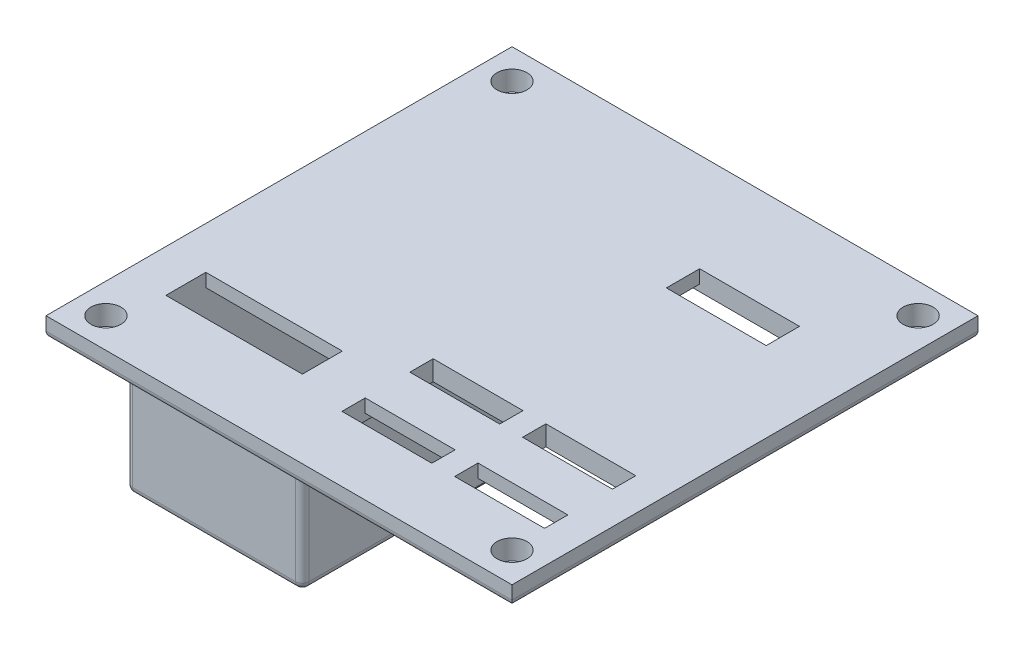
from build123d import *

# Parameters (mm, degrees)
BOSS_EXTRUDE1_DEPTH                        = 3
SKETCH4_R                                  = 2.250000000000006
CUT_EXTRUDE2_DEPTH                         = 3
MIRROR1_AT_THE_SECOND_PLANE_COPY_1_SKETC_R = 2.250000000000006
MIRROR1_AT_THE_SECOND_PLANE_COPY_1_DEPTH   = 3
FILLET4_R                                  = 1
CUT_EXTRUDE3_DEPTH                         = 1
SKETCH6_W                                  = 27.499999999999993
SKETCH6_H                                  = 27.999999999999996
CUT_EXTRUDE4_DEPTH                         = 1
CUT_EXTRUDE5_DEPTH                         = 3
SKETCH8_W                                  = 13.499999999999996
SKETCH8_H                                  = 13.700000000000003
CUT_EXTRUDE6_DEPTH                         = 1
SKETCH9_W                                  = 13.5
SKETCH9_H                                  = 3.5000000000000036
CUT_EXTRUDE7_DEPTH                         = 3
SKETCH10_W                                 = 13.499999999999996
SKETCH10_H                                 = 3.5000000000000036
SKETCH10_H_2                               = 3.5000000000000018
CUT_EXTRUDE8_DEPTH                         = 3
BOSS_EXTRUDE2_DEPTH                        = 23.5
CUT_EXTRUDE9_DEPTH                         = 29
SKETCH13_W                                 = 20.500000000000004
SKETCH13_H                                 = 6.0000000000000036
CUT_EXTRUDE10_DEPTH                        = 3
FILLET5_R                                  = 1
FILLET6_R                                  = 1
SKETCH14_W                                 = 20.8
SKETCH14_H                                 = 3.0000000000000036
CUT_EXTRUDE11_DEPTH                        = 1


with BuildPart() as part:
    # Sketch1 → Boss-Extrude1 (new body)
    with BuildSketch(Plane(origin=(0, 0, 0), x_dir=(1, 0, 0), z_dir=(0, 1, 0))):
        Polygon((-35, 35.00000000000001), (35, 35.00000000000001), (35.000000000000014, -34.99999999999999), (-35, -34.99999999999999), align=None)
    extrude(amount=BOSS_EXTRUDE1_DEPTH)

    # Sketch4 → Cut-Extrude2 (cut)
    with BuildSketch(Plane(origin=(0, 0, 0), x_dir=(-1, 0, 0), z_dir=(0, -1, 0))):
        with Locations(Location((30.500000000000004, -30.499999999999993, 0), (0, 0, 90))):
            Circle(SKETCH4_R)
    cut_extrude2 = extrude(amount=-CUT_EXTRUDE2_DEPTH, mode=Mode.SUBTRACT)

    # Mirror1: Cut-Extrude2 across plane
    add(cut_extrude2.mirror(Plane(origin=(0, 0, 0), x_dir=(0, 0, 1), z_dir=(1, 0, 0))), mode=Mode.SUBTRACT)

    # Mirror1 at the second plane: Cut-Extrude2 across plane
    add(cut_extrude2.mirror(Plane.XY), mode=Mode.SUBTRACT)

    # Mirror1 at the second plane copy 1 sketc → Mirror1 at the second plane copy 1 (cut)
    with BuildSketch(Plane.XZ):
        with Locations(Location((30.500000000000004, -30.499999999999993, 0), (0, 0, 90))):
            Circle(MIRROR1_AT_THE_SECOND_PLANE_COPY_1_SKETC_R)
    extrude(amount=-MIRROR1_AT_THE_SECOND_PLANE_COPY_1_DEPTH, mode=Mode.SUBTRACT)

    # Fillet4
    fillet4_edges = [part.edges().sort_by_distance(p)[0] for p in [
        (7.11e-15, 0, 34.99999999999999),
        (-35, 0, -7.11e-15),
        (0, 0, -35.00000000000001),
        (35.00000000000001, 0, -7.11e-15),
    ]]
    fillet(fillet4_edges, radius=FILLET4_R)

    # Sketch5 → Cut-Extrude3 (cut)
    with BuildSketch(Plane(origin=(0, 0, 0), x_dir=(-1, 0, 0), z_dir=(0, -1, 0))):
        Polygon((28.79465847473562, -24.725896818258043), (7.994658474735617, -24.725896818258047), (7.994658474735617, 20.774103181741953), (28.79465847473562, 20.774103181741957), align=None)
    extrude(amount=-CUT_EXTRUDE3_DEPTH, mode=Mode.SUBTRACT)

    # Sketch6 → Cut-Extrude4 (cut)
    with BuildSketch(Plane.XZ):
        with Locations((15.477858409688114, -6.209961428811168)):
            Rectangle(SKETCH6_W, SKETCH6_H)
    extrude(amount=-CUT_EXTRUDE4_DEPTH, mode=Mode.SUBTRACT)

    # Sketch7 → Cut-Extrude5 (cut)
    with BuildSketch(Plane(origin=(0, 1, 0), x_dir=(-1, 0, 0), z_dir=(0, -1, 0))):
        Polygon((-7.977858409688114, 15.209961428811162), (-22.977858409688114, 15.20996142881116), (-22.977858409688114, 20.209961428811166), (-7.977858409688114, 20.209961428811166), align=None)
    extrude(amount=-CUT_EXTRUDE5_DEPTH, mode=Mode.SUBTRACT)

    # Sketch8 → Cut-Extrude6 (cut)
    with BuildSketch(Plane.XZ):
        Polygon((-0.32931613637633694, 25.216207013959828), (13.170683863623664, 25.216207013959828), (13.170683863623664, 11.516207013959828), (-0.3293161363763353, 11.516207013959828), align=None)
        with Locations((23.356942305835496, 18.36620701395983)):
            Rectangle(SKETCH8_W, SKETCH8_H)
    extrude(amount=-CUT_EXTRUDE6_DEPTH, mode=Mode.SUBTRACT)

    # Sketch9 → Cut-Extrude7 (cut)
    with BuildSketch(Plane(origin=(0, 1, 0), x_dir=(-1, 0, 0), z_dir=(0, -1, 0))):
        with Locations((-6.420683863623664, -23.46620701395983)):
            Rectangle(SKETCH9_W, SKETCH9_H)
        Polygon((0.3293161363763353, -11.516207013959828), (-13.170683863623664, -11.51620701395983), (-13.170683863623664, -15.01620701395983), (0.3293161363763357, -15.016207013959828), align=None)
    extrude(amount=-CUT_EXTRUDE7_DEPTH, mode=Mode.SUBTRACT)

    # Sketch10 → Cut-Extrude8 (cut)
    with BuildSketch(Plane.XZ.offset(-1)):
        with Locations((23.356942305835496, 23.46620701395983)):
            Rectangle(SKETCH10_W, SKETCH10_H)
        with Locations((23.356942305835496, 13.266207013959828)):
            Rectangle(SKETCH10_W, SKETCH10_H_2)
    extrude(amount=-CUT_EXTRUDE8_DEPTH, mode=Mode.SUBTRACT)

    # Sketch11 → Boss-Extrude2 (add)
    with BuildSketch(Plane(origin=(0, 1, 0), x_dir=(-1, 0, 0), z_dir=(0, -1, 0))):
        Polygon((31.644658474735618, -26.345290910107266), (5.144658474735617, -26.34529091010727), (5.144658474735617, 5.654709089892729), (31.644658474735618, 5.654709089892732), align=None)
    extrude(amount=BOSS_EXTRUDE2_DEPTH)

    # Sketch12 → Cut-Extrude9 (cut)
    with BuildSketch(Plane(origin=(5.6e-16, 0, -5.654709089892728), x_dir=(-1, 0, -1e-16), z_dir=(1e-16, 0, -1))):
        Polygon((8.144658474735618, 1), (28.644658474735618, 1), (28.64465847473562, -19.5), (8.14465847473562, -19.5), align=None)
    extrude(amount=-CUT_EXTRUDE9_DEPTH, mode=Mode.SUBTRACT)

    # Sketch13 → Cut-Extrude10 (cut)
    with BuildSketch(Plane.XZ.offset(-1)):
        with Locations((-18.39465847473562, 20.345290910107273)):
            Rectangle(SKETCH13_W, SKETCH13_H)
    extrude(amount=-CUT_EXTRUDE10_DEPTH, mode=Mode.SUBTRACT)

    # Fillet5
    fillet5_edges = [part.edges().sort_by_distance(p)[0] for p in [
        (-5.144658474735617, -11.25, 26.34529091010727),
        (-31.644658474735618, -11.25, 26.345290910107266),
        (-5.144658474735617, -11.25, -5.654709089892729),
        (-31.644658474735618, -11.25, -5.654709089892732),
        (-28.64465847473562, -9.25, -5.654709089892731),
        (-18.39465847473562, -19.5, -5.65470908989273),
        (-8.144658474735618, -9.25, -5.654709089892729),
        (-18.394658474735618, -22.5, 26.345290910107266),
        (-5.144658474735617, -22.5, 10.34529091010727),
        (-18.394658474735618, -22.5, -5.65470908989273),
        (-31.644658474735618, -22.5, 10.345290910107268),
    ]]
    fillet(fillet5_edges, radius=FILLET5_R)

    # Fillet6
    fillet6_edges = [part.edges().sort_by_distance(p)[0] for p in [
        (-18.394658474735618, 0, 26.345290910107266),
        (-5.144658474735617, 0, 10.34529091010727),
        (-31.644658474735618, 0, 10.345290910107266),
        (-6.644658474735618, 0, -5.654709089892728),
        (-30.144658474735618, 0, -5.654709089892731),
        (-5.43755169354907, 0, 26.052397691293816),
        (-31.351765255922164, 0, 26.052397691293812),
        (-5.437551693549068, 0, -5.361815871079277),
        (-31.351765255922164, 0, -5.361815871079279),
        (-29.15823411660915, -8e-17, -5.528431782639838),
        (-7.631082832861968, 4e-17, -5.528431782639901),
    ]]
    fillet(fillet6_edges, radius=FILLET6_R)

    # Sketch14 → Cut-Extrude11 (cut)
    with BuildSketch(Plane.XZ):
        with Locations((-18.394658474735618, -22.274103181741957)):
            Rectangle(SKETCH14_W, SKETCH14_H)
    extrude(amount=-CUT_EXTRUDE11_DEPTH, mode=Mode.SUBTRACT)


solid = part.part
